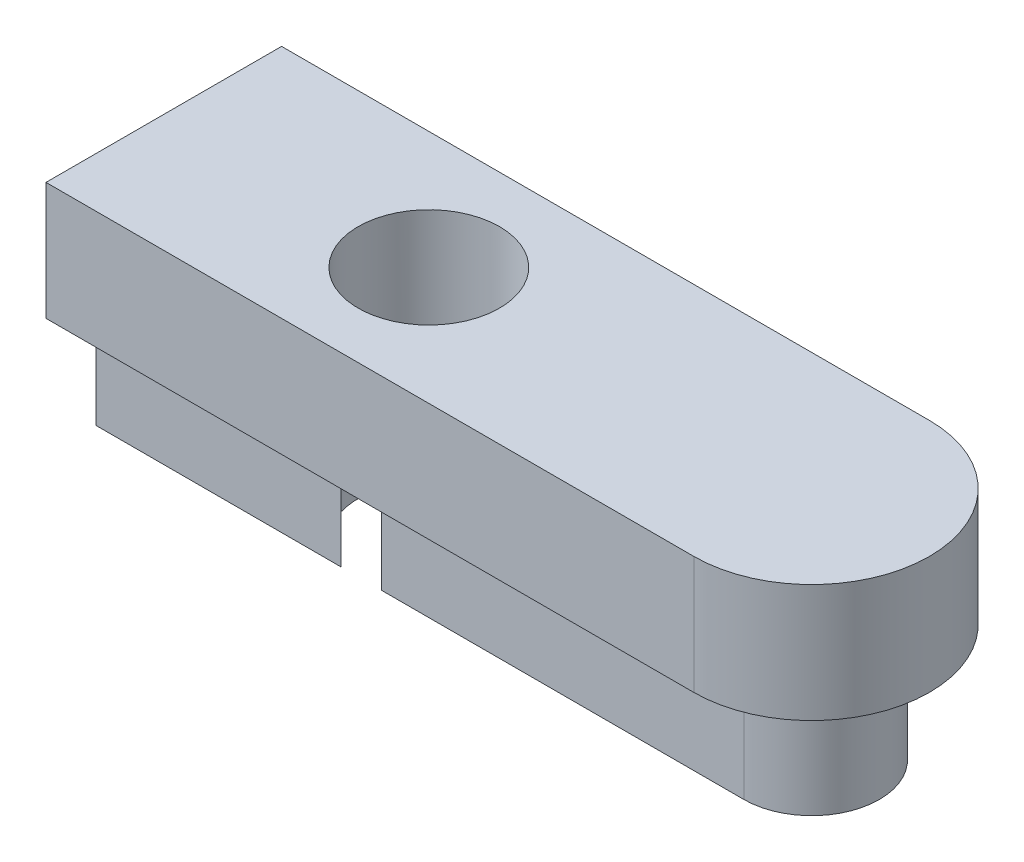
from build123d import *

# Parameters (mm, degrees)
BOSS_EXTRUDE1_DEPTH = 2
BOSS_EXTRUDE2_DEPTH = 2
SKETCH3_R           = 1.2
CUT_EXTRUDE1_DEPTH  = 5
SKETCH4_W           = 6
SKETCH4_H           = 6
CUT_EXTRUDE2_DEPTH  = 5


with BuildPart() as part:
    # Sketch1 → Boss-Extrude1 (new body)
    with BuildSketch(Plane(origin=(0, 0, 0), x_dir=(1, 0, 0), z_dir=(0, 1, 0))):
        with BuildLine():
            Line((-6.5, 2), (6.5, 2))
            ThreePointArc((6.5, 2), (8.5, 0), (6.5, -2))
            Line((6.5, -2), (-6.5, -2))
            ThreePointArc((-6.5, -2), (-8.5, 0), (-6.5, 2))
        make_face()
    extrude(amount=BOSS_EXTRUDE1_DEPTH)

    # Sketch2 → Boss-Extrude2 (add)
    with BuildSketch(Plane.XZ):
        with BuildLine():
            Line((-6.5, 1.15), (6.5, 1.15))
            ThreePointArc((6.5, 1.15), (7.65, 0), (6.5, -1.15))
            Line((6.5, -1.15), (-6.5, -1.15))
            ThreePointArc((-6.5, -1.15), (-7.65, 0), (-6.5, 1.15))
        make_face()
    extrude(amount=BOSS_EXTRUDE2_DEPTH)

    # Sketch3 → Cut-Extrude1 (cut, through all)
    with BuildSketch(Plane.XZ.offset(2)):
        Circle(SKETCH3_R)
    extrude(amount=-CUT_EXTRUDE1_DEPTH, mode=Mode.SUBTRACT)

    # Sketch4 → Cut-Extrude2 (cut, through all)
    with BuildSketch(Plane.XZ.offset(2)):
        with Locations((-7.5, 0)):
            Rectangle(SKETCH4_W, SKETCH4_H)
    extrude(amount=-CUT_EXTRUDE2_DEPTH, mode=Mode.SUBTRACT)


solid = part.part
